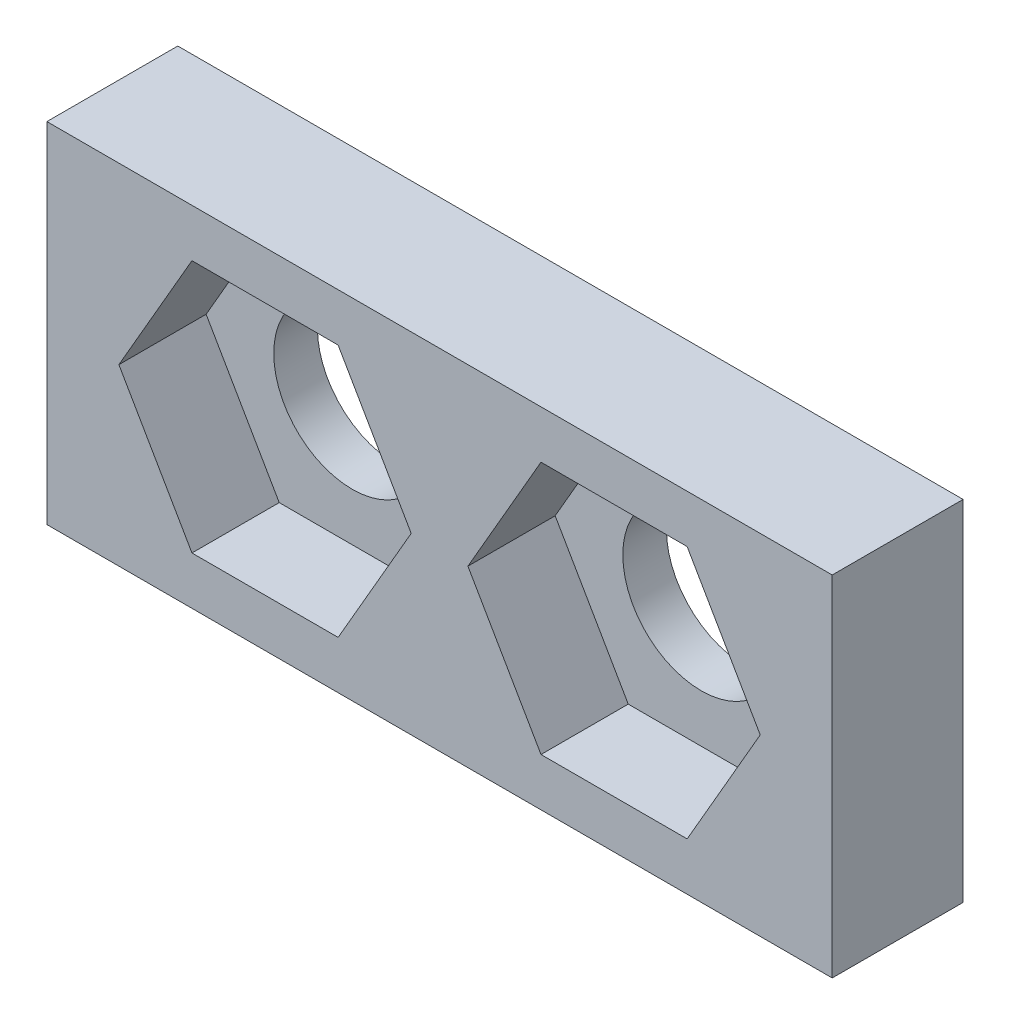
from build123d import *

# Parameters (mm, degrees)
SKETCH_1_W                  = 18
SKETCH_1_H                  = 8
EXTRUDE_1_DEPTH             = 3
CUT_EXTRUDE_1_DEPTH         = 2
CUT_EXTRUDE_2_DEPTH         = 2
HOLE_WIZARD_3_6_3_6_1_D     = 3.6
HOLE_WIZARD_3_6_3_6_1_DEPTH = 3


with BuildPart() as part:
    # 草图1 → 凸台-拉伸1 (new body)
    with BuildSketch(Plane(origin=(0, 0, 0), x_dir=(-1, 0, 0), z_dir=(0, 0, -1))):
        with Locations((0, 300)):
            Rectangle(SKETCH_1_W, SKETCH_1_H)
    extrude(amount=-EXTRUDE_1_DEPTH)

    # 草图2 → 切除-拉伸1 (cut)
    with BuildSketch(Plane.XY.offset(3)):
        Polygon((-0.65, 300), (-2.325, 302.901185103), (-5.675, 302.901185103), (-7.35, 300), (-5.675, 297.098814897), (-2.325, 297.098814897), align=None)
    extrude(amount=-CUT_EXTRUDE_1_DEPTH, mode=Mode.SUBTRACT)

    # 草图3 → 切除-拉伸2 (cut)
    with BuildSketch(Plane.XY.offset(3)):
        Polygon((5.675, 297.098814897), (7.35, 300), (5.675, 302.901185103), (2.325, 302.901185103), (0.65, 300), (2.325, 297.098814897), align=None)
    extrude(amount=-CUT_EXTRUDE_2_DEPTH, mode=Mode.SUBTRACT)

    # Ø3.6 (3.6) 直径孔1
    with Locations(Plane(origin=(0, 0, 0), x_dir=(-1, 0, 0), z_dir=(0, 0, -1))):
        with Locations((-4, 300), (4, 300)):
            Hole(HOLE_WIZARD_3_6_3_6_1_D / 2, depth=HOLE_WIZARD_3_6_3_6_1_DEPTH)


solid = part.part
